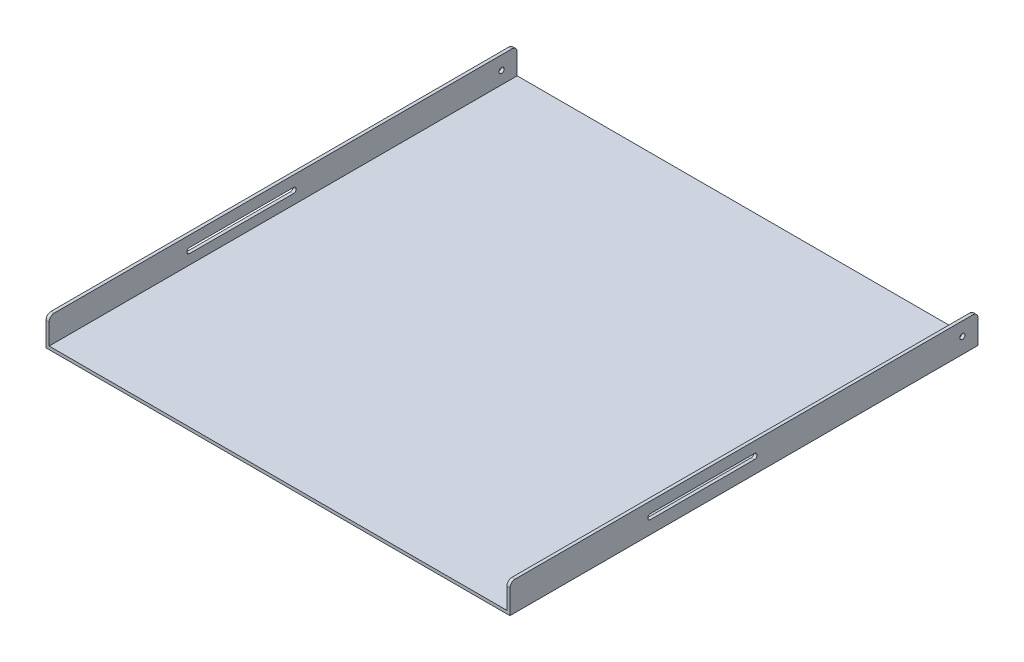
from build123d import *

# Parameters (mm, degrees)
EXTRUDE_THIN1_DEPTH = 450
SKETCH2_R           = 5
CUT_EXTRUDE1_DEPTH  = 893
FILLET1_R           = 10


with BuildPart() as part:
    # Sketch1 → Extrude-Thin1 (new body, symmetric)
    with BuildSketch(Plane.XY):
        Polygon((-250, 50), (-250, 0), (630, 0), (630, 50), (636, 50), (636, -6), (-256, -6), (-256, 50), align=None)
    extrude(amount=EXTRUDE_THIN1_DEPTH, both=True)

    # Sketch2 → Cut-Extrude1 (cut, through all)
    with BuildSketch(Plane(origin=(636, 0, 0), x_dir=(0, 0, -1), z_dir=(1, 0, 0))):
        with Locations((420, 24)):
            Circle(SKETCH2_R)
        with BuildLine():
            Line((20, 19), (-180, 19))
            ThreePointArc((-180, 19), (-185, 24), (-180, 29))
            Line((-180, 29), (20, 29))
            ThreePointArc((20, 29), (25, 24), (20, 19))
        make_face()
    extrude(amount=-CUT_EXTRUDE1_DEPTH, mode=Mode.SUBTRACT)

    # Fillet1
    fillet1_edges = [part.edges().sort_by_distance(p)[0] for p in [
        (-253, 50, 450),
        (-253, 50, -450),
        (633, 50, 450),
        (633, 50, -450),
    ]]
    fillet(fillet1_edges, radius=FILLET1_R)


solid = part.part
